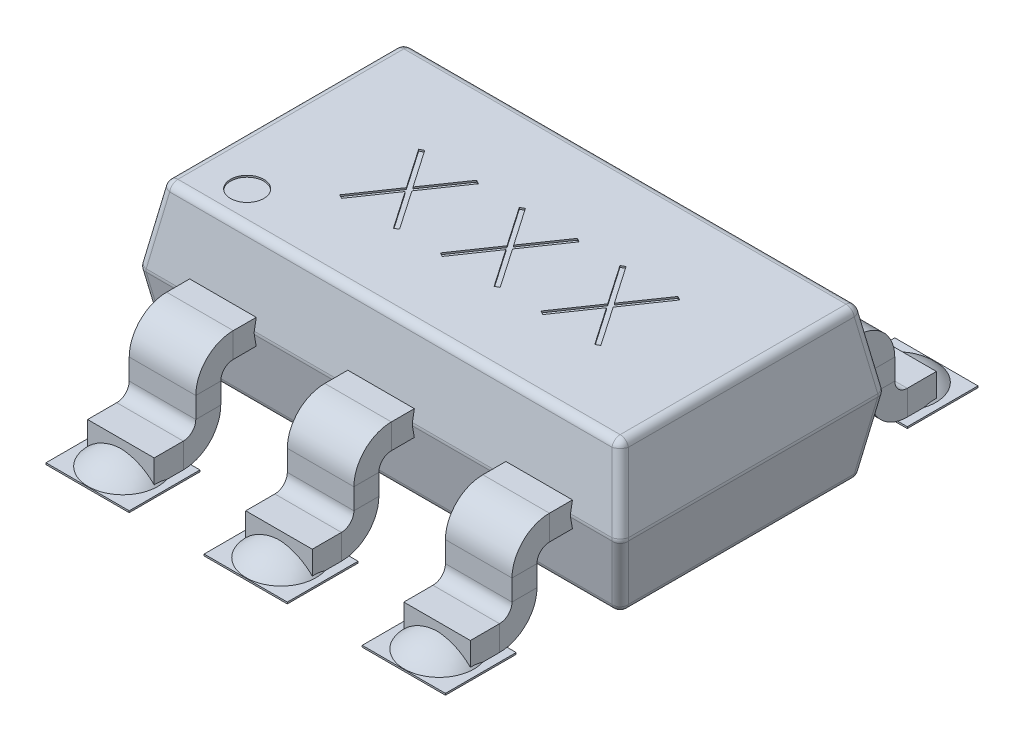
from build123d import *

# Parameters (mm, degrees)
CROQUIS1_W                        = 2.9
CROQUIS1_H                        = 1.6
SALIENTE_EXTRUIR1_DEPTH           = 0.45
SALIENTE_EXTRUIR1_TAPER           = 10
SALIENTE_EXTRUIR1_OTHER_WAY_DEPTH = 0.45
SALIENTE_EXTRUIR1_OTHER_WAY_TAPER = 10
CROQUIS2_R                        = 0.1
CORTAR_EXTRUIR1_DEPTH             = 0.01
REDONDEO1_R                       = 0.05
CROQUIS3_W                        = 0.4
CROQUIS3_H                        = 0.15
CROQUIS5_W                        = 0.5
CROQUIS5_H                        = 0.425
SALIENTE_EXTRUIR2_DEPTH           = 0.01
MATRIZL1_COUNT                    = 2
MATRIZL1_PITCH                    = 0.95
MATRIZL1_2_COUNT                  = 2
MATRIZL1_2_PITCH                  = 0.95


with BuildPart() as part:
    # Croquis1 → Saliente-Extruir1 (new body)
    with BuildSketch(Plane(origin=(0, 0, 0), x_dir=(1, 0, 0), z_dir=(0, 1, 0))):
        Rectangle(CROQUIS1_W, CROQUIS1_H)
    extrude(amount=SALIENTE_EXTRUIR1_DEPTH, taper=SALIENTE_EXTRUIR1_TAPER)

    # Croquis1 → Saliente-Extruir1 other way (add)
    with BuildSketch(Plane(origin=(0, 0, 0), x_dir=(1, 0, 0), z_dir=(0, 1, 0))):
        Rectangle(CROQUIS1_W, CROQUIS1_H)
    extrude(amount=-SALIENTE_EXTRUIR1_OTHER_WAY_DEPTH, taper=SALIENTE_EXTRUIR1_OTHER_WAY_TAPER)

    # Croquis2 → Cortar-Extruir1 (cut)
    with BuildSketch(Plane(origin=(0, 0.45, 0), x_dir=(1, 0, 0), z_dir=(0, 1, 0))):
        with Locations((-1.070652859, -0.520652859)):
            Circle(CROQUIS2_R)
        Polygon((-0.761865061, 0.20112029), (-0.737714266, 0.213392036), (-0.58230488, -0.012211734), (-0.426208277, 0.213784732), (-0.402744699, 0.200825768), (-0.565418958, -0.036068007), (-0.402744699, -0.272961783), (-0.426208277, -0.286215268), (-0.58230488, -0.059629759), (-0.737714266, -0.286215268), (-0.761865061, -0.273354479), (-0.59889628, -0.036068007), align=None)
        Polygon((-0.15707741, 0.20112029), (-0.132926615, 0.213392036), (0.02248277, -0.012211734), (0.178579373, 0.213784732), (0.202042951, 0.200825768), (0.039368692, -0.036068007), (0.202042951, -0.272961783), (0.178579373, -0.286215268), (0.02248277, -0.059629759), (-0.132926615, -0.286215268), (-0.15707741, -0.273354479), (0.00589137, -0.036068007), align=None)
        Polygon((0.44771024, 0.20112029), (0.471861035, 0.213392036), (0.627270421, -0.012211734), (0.783367024, 0.213784732), (0.806830601, 0.200825768), (0.644156342, -0.036068007), (0.806830601, -0.272961783), (0.783367024, -0.286215268), (0.627270421, -0.059629759), (0.471861035, -0.286215268), (0.44771024, -0.273354479), (0.610679021, -0.036068007), align=None)
    extrude(amount=-CORTAR_EXTRUIR1_DEPTH, mode=Mode.SUBTRACT)

    # Redondeo1
    redondeo1_edges = [part.edges().sort_by_distance(p)[0] for p in [
        (-1.370652859, -0.45, 0),
        (0, -0.45, 0.720652859),
        (1.410326429, 0.225, 0.760326429),
        (1.410326429, 0.225, -0.760326429),
        (-1.410326429, 0.225, -0.760326429),
        (-1.410326429, 0.225, 0.760326429),
        (1.370652859, 0.45, 0),
        (0, 0.45, -0.720652859),
        (-1.370652859, 0.45, 0),
        (0, 0.45, 0.720652859),
        (1.370652859, -0.45, 0),
        (0, 0, 0.8),
        (-1.45, 0, 0),
        (0, 0, -0.8),
        (1.45, 0, 0),
        (0, -0.45, -0.720652859),
        (1.410326429, -0.225, 0.760326429),
        (-1.410326429, -0.225, 0.760326429),
        (-1.410326429, -0.225, -0.760326429),
        (1.410326429, -0.225, -0.760326429),
    ]]
    fillet(redondeo1_edges, radius=REDONDEO1_R)


with BuildPart() as body_2:
    # Barrer1: sweep along a path in Croquis4
    with BuildLine(Plane(origin=(0, 0, 0), x_dir=(0, 0, -1), z_dir=(1, 0, 0))) as barrer1_path:
        Line((-1.4, -0.425), (-1.225, -0.425))
        ThreePointArc((-1.225, -0.425), (-1.118933983, -0.381066017), (-1.075, -0.275))
        Line((-1.075, -0.275), (-1.075, -0.15))
        ThreePointArc((-1.075, -0.15), (-1.031066017, -0.043933983), (-0.925, 0))
        Line((-0.925, 0), (0, 0))
    # Croquis3 → Barrer1 (sweep)
    with BuildSketch(Plane.XY.offset(1.4)):
        with Locations((0, -0.425)):
            Rectangle(CROQUIS3_W, CROQUIS3_H)
    sweep(path=barrer1_path.line)

    # Croquis5 → Saliente-Extruir2 (add)
    with BuildSketch(Plane.XZ.offset(0.5)):
        with Locations((0, 1.3875)):
            Rectangle(CROQUIS5_W, CROQUIS5_H)
    extrude(amount=SALIENTE_EXTRUIR2_DEPTH)

    # Croquis6 → Revoluci_n1 (revolve)
    with BuildSketch(Plane.XY.offset(1.3875)):
        with BuildLine():
            Line((0, -0.5), (0, -0.400719471))
            ThreePointArc((0, -0.400719471), (0.114738426, -0.429448528), (0.209673957, -0.5))
            Line((0.209673957, -0.5), (0, -0.5))
        make_face()
    revolve(axis=Axis((0, -0.5, 1.3875), (0, 1, 0)))


with BuildPart() as matrizl1_1:
    # MatrizL1: pattern copy
    add(body_2.part.moved(Location(Vector(1, 0, 0) * (1 * MATRIZL1_PITCH))))


with BuildPart() as matrizl1_2_1:
    # MatrizL1 2: pattern copy
    add(body_2.part.moved(Location(Vector(-1, 0, 0) * (1 * MATRIZL1_2_PITCH))))


with BuildPart() as body_5:
    # Simetr_a1: mirrored copy
    add(matrizl1_2_1.part.mirror(Plane.XY))


with BuildPart() as body_6:
    # Simetr_a1 2: mirrored copy
    add(matrizl1_1.part.mirror(Plane.XY))


solid = Compound([part.part, body_2.part, matrizl1_1.part, matrizl1_2_1.part, body_5.part, body_6.part])
